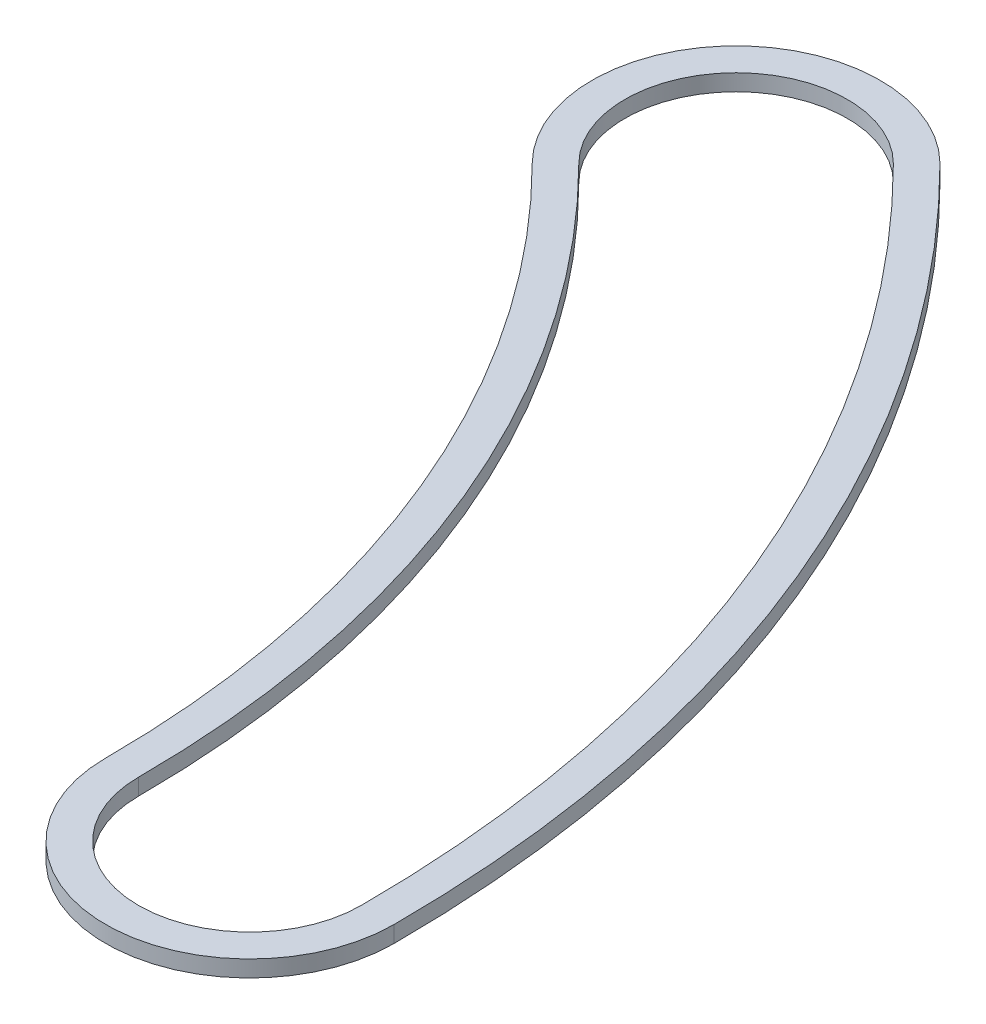
from build123d import *

# Parameters (mm, degrees)
BOSS_EXTRUDE1_DEPTH = 0.508


with BuildPart() as part:
    # Sketch1 → Boss-Extrude1 (new body)
    with BuildSketch(Plane(origin=(0, 0, 0), x_dir=(1, 0, 0), z_dir=(0, 1, 0))):
        with BuildLine():
            ThreePointArc((40.64, 0), (37.546464201, 15.552254691), (28.736819587, 28.736819587))
            ThreePointArc((28.736819587, 28.736819587), (22.450640303, 28.736819587), (22.450640303, 22.450640303))
            ThreePointArc((22.450640303, 22.450640303), (29.333175157, 12.150198978), (31.75, 0))
            ThreePointArc((31.75, 0), (36.195, -4.445), (40.64, 0))
        make_face()
        with BuildLine():
            ThreePointArc((39.624, 0), (36.607802596, 15.163448324), (28.018399098, 28.018399098))
            ThreePointArc((28.018399098, 28.018399098), (23.169060792, 28.018399098), (23.169060792, 23.169060792))
            ThreePointArc((23.169060792, 23.169060792), (30.271836762, 12.539005345), (32.766, 0))
            ThreePointArc((32.766, 0), (36.195, -3.429), (39.624, 0))
        make_face(mode=Mode.SUBTRACT)
    extrude(amount=BOSS_EXTRUDE1_DEPTH)


solid = part.part
